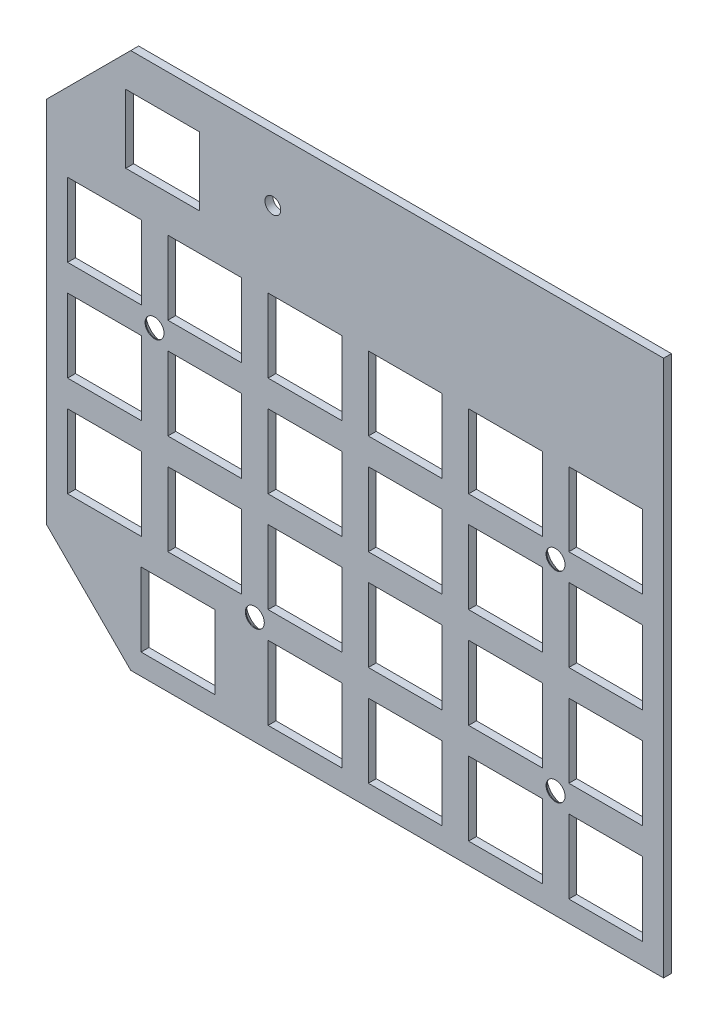
from build123d import *

# Parameters (mm, degrees)
BOSS_EXTRU_1_DEPTH                          = 1.5
ESQUISSE3_R                                 = 1.5
ESQUISSE3_W                                 = 14
ESQUISSE3_H                                 = 14
ESQUISSE3_H_2                               = 13
ENL_V_MAT_EXTRU_2_DEPTH                     = 10
FRAISAGE_POUR_VIS_T_TE_FRAIS_E_M31_AT_COUNT = 2
FRAISAGE_POUR_VIS_T_TE_FRAIS_E_M31_AT_PITCH = 38.1
FRAISAGE_POUR_VIS_T_TE_FRAIS_E_M31_2_COUNT  = 2
FRAISAGE_POUR_VIS_T_TE_FRAIS_E_M31_2_PITCH  = 76.2
FRAISAGE_POUR_VIS_T_TE_FRAIS_E_M31_3_COUNT  = 2
FRAISAGE_POUR_VIS_T_TE_FRAIS_E_M31_3_PITCH  = 68.685751798


with BuildPart() as part:
    # Esquisse1 → Boss.-Extru.1 (new body)
    with BuildSketch(Plane.XY):
        Polygon((0, -85), (16, -101), (117.25, -101), (117.25, 1), (16, 1), (0, -15), align=None)
    extrude(amount=BOSS_EXTRU_1_DEPTH)

    # Esquisse3 → Enlèv. mat.-Extru.2 (cut)
    with BuildSketch(Plane(origin=(0, 0, 0), x_dir=(-1, 0, 0), z_dir=(0, 0, -1))):
        with Locations((-43, -11)):
            Circle(ESQUISSE3_R)
        with Locations((-87.2, -32.85)):
            Rectangle(ESQUISSE3_W, ESQUISSE3_H)
        with Locations((-106.25, -32.85)):
            Rectangle(ESQUISSE3_W, ESQUISSE3_H)
        with Locations((-68.15, -32.85)):
            Rectangle(ESQUISSE3_W, ESQUISSE3_H)
        with Locations((-49.1, -32.85)):
            Rectangle(ESQUISSE3_W, ESQUISSE3_H)
        with Locations((-30.05, -32.85)):
            Rectangle(ESQUISSE3_W, ESQUISSE3_H)
        with Locations((-11, -32.85)):
            Rectangle(ESQUISSE3_W, ESQUISSE3_H)
        with Locations((-87.2, -51.9)):
            Rectangle(ESQUISSE3_W, ESQUISSE3_H)
        with Locations((-68.15, -51.9)):
            Rectangle(ESQUISSE3_W, ESQUISSE3_H)
        with Locations((-49.1, -51.9)):
            Rectangle(ESQUISSE3_W, ESQUISSE3_H)
        with Locations((-30.05, -51.9)):
            Rectangle(ESQUISSE3_W, ESQUISSE3_H)
        with Locations((-11, -51.9)):
            Rectangle(ESQUISSE3_W, ESQUISSE3_H)
        with Locations((-87.2, -70.95)):
            Rectangle(ESQUISSE3_W, ESQUISSE3_H)
        with Locations((-68.15, -70.95)):
            Rectangle(ESQUISSE3_W, ESQUISSE3_H)
        with Locations((-49.1, -70.95)):
            Rectangle(ESQUISSE3_W, ESQUISSE3_H)
        with Locations((-30.05, -70.95)):
            Rectangle(ESQUISSE3_W, ESQUISSE3_H)
        with Locations((-11, -70.95)):
            Rectangle(ESQUISSE3_W, ESQUISSE3_H)
        with Locations((-87.2, -90)):
            Rectangle(ESQUISSE3_W, ESQUISSE3_H)
        with Locations((-68.15, -90)):
            Rectangle(ESQUISSE3_W, ESQUISSE3_H)
        with Locations((-49.1, -90)):
            Rectangle(ESQUISSE3_W, ESQUISSE3_H)
        with Locations((-106.25, -51.9)):
            Rectangle(ESQUISSE3_W, ESQUISSE3_H)
        with Locations((-106.25, -70.95)):
            Rectangle(ESQUISSE3_W, ESQUISSE3_H)
        with Locations((-106.25, -90)):
            Rectangle(ESQUISSE3_W, ESQUISSE3_H)
        with Locations((-24.97, -90)):
            Rectangle(ESQUISSE3_W, ESQUISSE3_H)
        with Locations((-22.05, -12.35)):
            Rectangle(ESQUISSE3_W, ESQUISSE3_H_2)
    extrude(amount=-ENL_V_MAT_EXTRU_2_DEPTH, mode=Mode.SUBTRACT)

    # Esquisse6 → Fraisage pour vis à tête fraisée M31 (revolve, cut)
    with BuildSketch(Plane(origin=(96.725, -42.375, 0), x_dir=(0, 1, 0), z_dir=(1, 0, 0))):
        Polygon((0, 0), (0, 1.5), (1.8, 1.5), (1.8, 1.35), (3.15, 0), align=None)
    fraisage_pour_vis_t_te_frais_e_m31 = revolve(axis=Axis((96.725, -42.375, -6.35), (0, 0, 1)), mode=Mode.SUBTRACT)

    # Fraisage pour vis à tête fraisée M31 at: Fraisage pour vis à tête fraisée M31 ×2
    with Locations(*[(0, -i * FRAISAGE_POUR_VIS_T_TE_FRAIS_E_M31_AT_PITCH, 0) for i in range(1, FRAISAGE_POUR_VIS_T_TE_FRAIS_E_M31_AT_COUNT)]):
        add(fraisage_pour_vis_t_te_frais_e_m31, mode=Mode.SUBTRACT)

    # Fraisage pour vis _ t_te frais_e M31 2: Fraisage pour vis à tête fraisée M31 ×2
    with Locations(*[(-i * FRAISAGE_POUR_VIS_T_TE_FRAIS_E_M31_2_PITCH, 0, 0) for i in range(1, FRAISAGE_POUR_VIS_T_TE_FRAIS_E_M31_2_COUNT)]):
        add(fraisage_pour_vis_t_te_frais_e_m31, mode=Mode.SUBTRACT)

    # Fraisage pour vis _ t_te frais_e M31 3: Fraisage pour vis à tête fraisée M31 ×2
    with Locations(*[Vector(-0.832050294, -0.554700196, 0) * (i * FRAISAGE_POUR_VIS_T_TE_FRAIS_E_M31_3_PITCH) for i in range(1, FRAISAGE_POUR_VIS_T_TE_FRAIS_E_M31_3_COUNT)]):
        add(fraisage_pour_vis_t_te_frais_e_m31, mode=Mode.SUBTRACT)


solid = part.part
